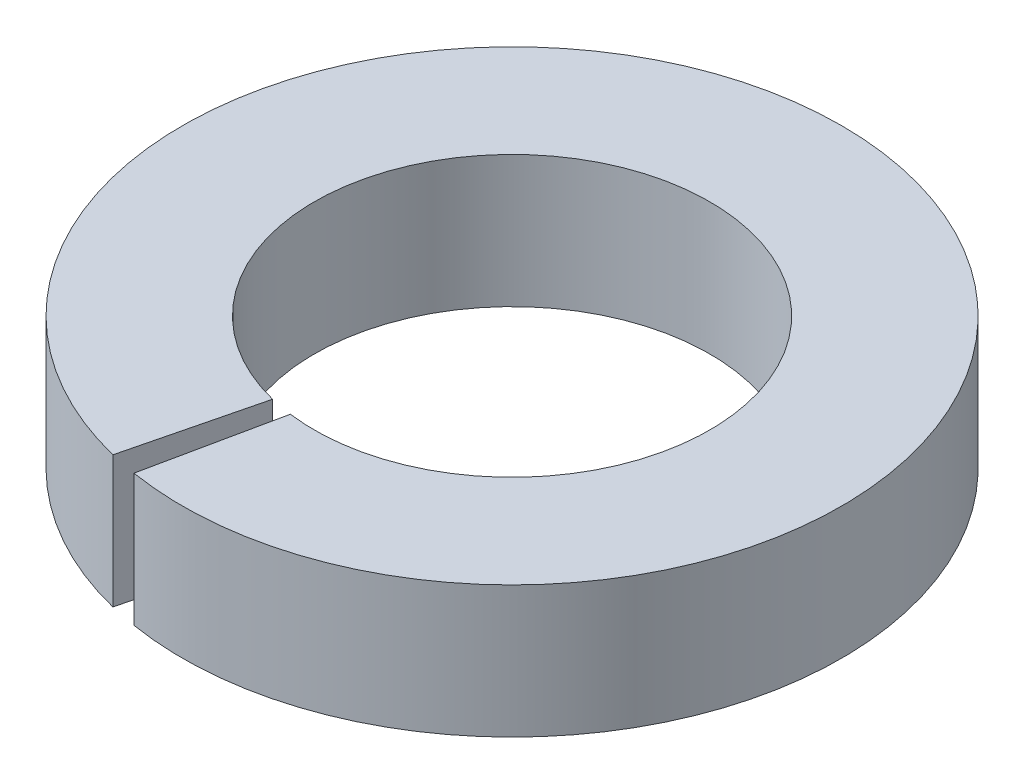
from build123d import *

# Parameters (mm, degrees)
EXTRUDE_1_DEPTH = 1


with BuildPart() as part:
    # Эскиз1 → Бобышка-Вытянуть1 (new body)
    with BuildSketch(Plane(origin=(0, 0, 0), x_dir=(1, 0, 0), z_dir=(0, 1, 0))):
        with BuildLine():
            Line((-0.360733904, -1.455977696), (-0.601223173, -2.426629493))
            ThreePointArc((-0.601223173, -2.426629493), (0.501439159, 2.449195535), (-0.400815449, -2.467660223))
            Line((-0.400815449, -2.467660223), (-0.194846131, -1.487291157))
            ThreePointArc((-0.194846131, -1.487291157), (0.278230888, 1.473970004), (-0.360733904, -1.455977696))
        make_face()
    extrude(amount=EXTRUDE_1_DEPTH)


solid = part.part
